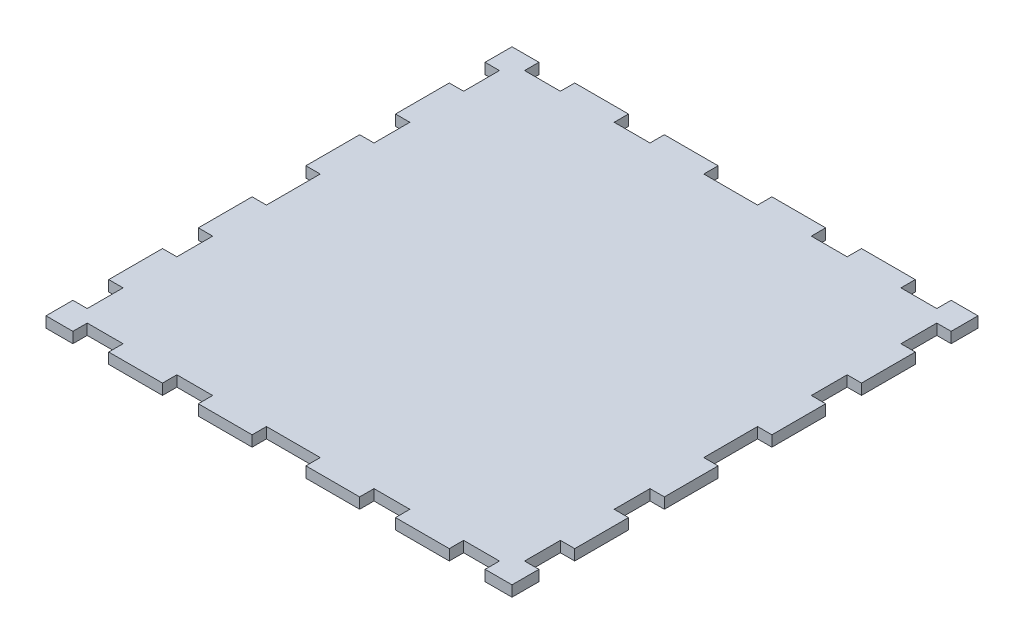
from build123d import *

# Parameters (mm, degrees)
BOSS_EXTRUDE1_DEPTH = 3


with BuildPart() as part:
    # Sketch1 → Boss-Extrude1 (new body)
    with BuildSketch(Plane(origin=(0, 0, 0), x_dir=(1, 0, 0), z_dir=(0, 1, 0))):
        Polygon((-65, -65), (-57.5, -65), (-57.5, -61), (-47.5, -61), (-47.5, -65), (-32.5, -65), (-32.5, -61), (-22.5, -61), (-22.5, -65), (-7.5, -65), (-7.5, -61), (7.5, -61), (7.5, -65), (22.5, -65), (22.5, -61), (32.5, -61), (32.5, -65), (47.5, -65), (47.5, -61), (57.5, -61), (57.5, -65), (65, -65), (65, -57.5), (61, -57.5), (61, -47.5), (65, -47.5), (65, -32.5), (61, -32.5), (61, -22.5), (65, -22.5), (65, -7.5), (61, -7.5), (61, 7.5), (65, 7.5), (65, 22.5), (61, 22.5), (61, 32.5), (65, 32.5), (65, 47.5), (61, 47.5), (61, 57.5), (65, 57.5), (65, 65), (57.5, 65), (57.5, 61), (47.5, 61), (47.5, 65), (32.5, 65), (32.5, 61), (22.5, 61), (22.5, 65), (7.5, 65), (7.5, 61), (-7.5, 61), (-7.5, 65), (-22.5, 65), (-22.5, 61), (-32.5, 61), (-32.5, 65), (-47.5, 65), (-47.5, 61), (-57.5, 61), (-57.5, 65), (-65, 65), (-65, 57.5), (-61, 57.5), (-61, 47.5), (-65, 47.5), (-65, 32.5), (-61, 32.5), (-61, 22.5), (-65, 22.5), (-65, 7.5), (-61, 7.5), (-61, -7.5), (-65, -7.5), (-65, -22.5), (-61, -22.5), (-61, -32.5), (-65, -32.5), (-65, -47.5), (-61, -47.5), (-61, -57.5), (-65, -57.5), align=None)
    extrude(amount=BOSS_EXTRUDE1_DEPTH)


solid = part.part
